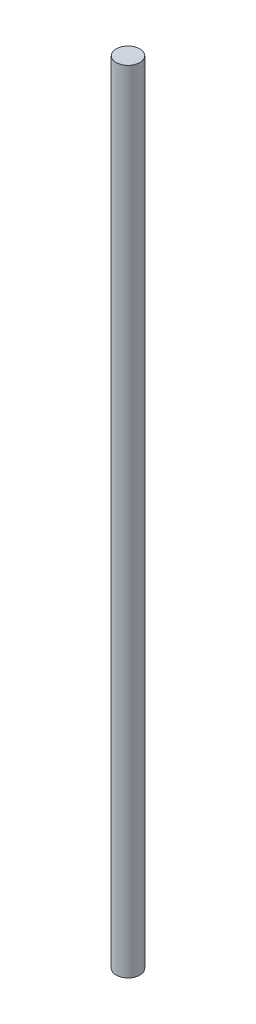
from build123d import *

# Parameters (mm, degrees)
CROQUIS1_R              = 3
SALIENTE_EXTRUIR1_DEPTH = 200


with BuildPart() as part:
    # Croquis1 → Saliente-Extruir1 (new body)
    with BuildSketch(Plane(origin=(0, 0, 0), x_dir=(1, 0, 0), z_dir=(0, 1, 0))):
        Circle(CROQUIS1_R)
    extrude(amount=SALIENTE_EXTRUIR1_DEPTH)


solid = part.part
